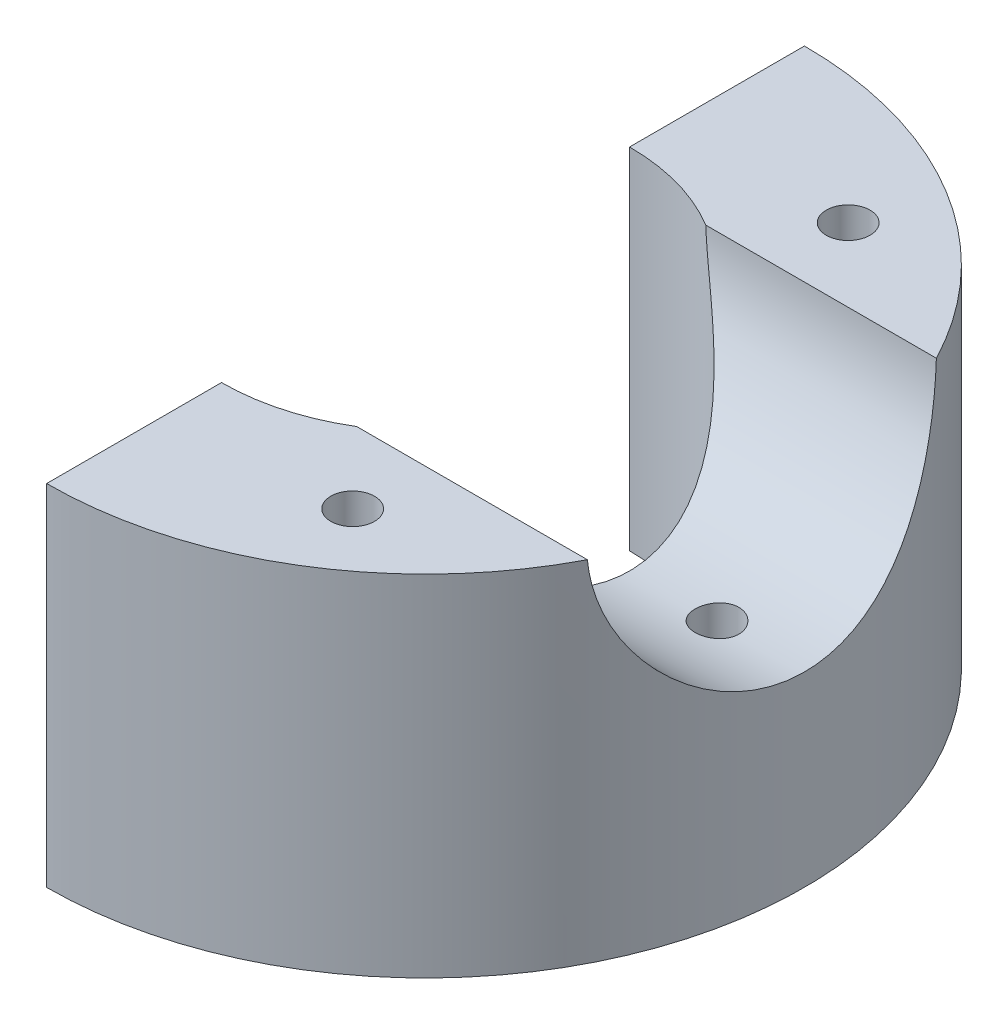
from build123d import *

# Parameters (mm, degrees)
BOSS_EXTRUDE1_DEPTH = 76.2
SKETCH2_R           = 6.35
CUT_EXTRUDE1_DEPTH  = 28.575
SKETCH4_R           = 38.1
CUT_EXTRUDE3_DEPTH  = 83.55
SKETCH5_R           = 4.7625
CUT_EXTRUDE4_DEPTH  = 77.2000001
SKETCH6_R           = 4.7625
CUT_EXTRUDE5_DEPTH  = 28.575


with BuildPart() as part:
    # Sketch1 → Boss-Extrude1 (new body)
    with BuildSketch(Plane(origin=(0, 0, 0), x_dir=(1, 0, 0), z_dir=(0, 1, 0))):
        with BuildLine():
            Line((0, 82.55), (0, 44.45))
            ThreePointArc((0, 44.45), (44.45, 0), (0, -44.45))
            Line((0, -44.45), (0, -82.55))
            ThreePointArc((0, -82.55), (82.55, 0), (0, 82.55))
        make_face()
    extrude(amount=BOSS_EXTRUDE1_DEPTH)

    # Sketch2 → Cut-Extrude1 (cut)
    with BuildSketch(Plane.ZY):
        with Locations((-63.5, 57.15)):
            Circle(SKETCH2_R)
        with Locations((-63.5, 19.05)):
            Circle(SKETCH2_R)
        with Locations((63.5, 19.05)):
            Circle(SKETCH2_R)
        with Locations((63.5, 57.15)):
            Circle(SKETCH2_R)
    extrude(amount=-CUT_EXTRUDE1_DEPTH, mode=Mode.SUBTRACT)

    # Sketch4 → Cut-Extrude3 (cut, through all)
    with BuildSketch(Plane.ZY):
        with Locations((0, 78.74)):
            Circle(SKETCH4_R)
    extrude(amount=-CUT_EXTRUDE3_DEPTH, mode=Mode.SUBTRACT)

    # Sketch5 → Cut-Extrude4 (cut, through all)
    with BuildSketch(Plane(origin=(0, 0, 0), x_dir=(-1, 0, 0), z_dir=(0, -1, 0))):
        with Locations((-63.5, 0)):
            Circle(SKETCH5_R)
    extrude(amount=-CUT_EXTRUDE4_DEPTH, mode=Mode.SUBTRACT)

    # Sketch6 → Cut-Extrude5 (cut)
    with BuildSketch(Plane(origin=(0, 76.2, 0), x_dir=(1, 0, 0), z_dir=(0, 1, 0))):
        with Locations((38.1, -53.975)):
            Circle(SKETCH6_R)
        with Locations((38.1, 53.975)):
            Circle(SKETCH6_R)
    extrude(amount=-CUT_EXTRUDE5_DEPTH, mode=Mode.SUBTRACT)


solid = part.part
